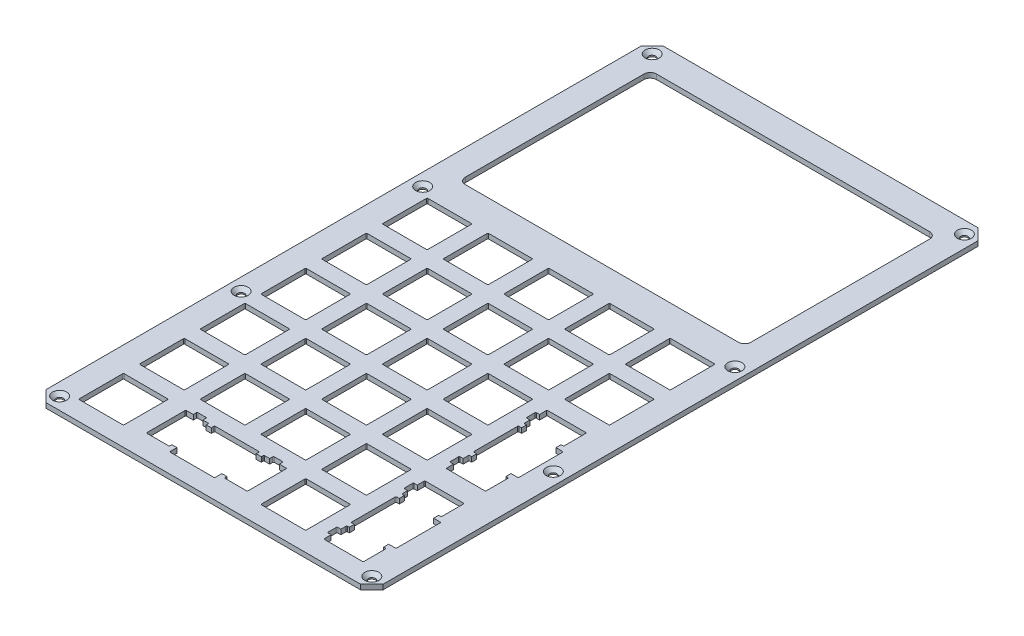
from build123d import *

# Parameters (mm, degrees)
SKETCH1_W           = 105
SKETCH1_H           = 192.3454
SKETCH1_W_2         = 13.9954
SKETCH1_H_2         = 13.9954
BOSS_EXTRUDE1_DEPTH = 1.524
FILLET1_R           = 0.25
CHAMFER1_SIZE       = 3.5
SKETCH3_R           = 1.1
CUT_EXTRUDE1_DEPTH  = 2.524
CHAMFER2_SIZE       = 1.1


with BuildPart() as part:
    # Sketch1 → Boss-Extrude1 (new body)
    with BuildSketch(Plane(origin=(0, 0, 0), x_dir=(1, 0, 0), z_dir=(0, 1, 0))):
        with Locations((37.846, -11.419)):
            Rectangle(SKETCH1_W, SKETCH1_H)
        Polygon((80.4243114, -40.3075), (82.6943114, -40.3075), (82.6943114, -54.3075), (80.4243114, -54.3075), (80.4243114, -55.8825), (81.2243114, -55.8825), (81.2243114, -63.0405), (68.9243114, -63.0405), (68.9243114, -60.7075), (67.7243114, -60.7075), (67.7243114, -57.7075), (68.9243114, -57.7075), (68.9243114, -55.8825), (69.7243114, -55.8825), (69.7243114, -54.3075), (68.6943, -54.3075), (68.6943, -40.3075), (69.7243114, -40.3075), (69.7243114, -38.7325), (68.9243114, -38.7325), (68.9243114, -36.9075), (67.7243114, -36.9075), (67.7243114, -33.9075), (68.9243114, -33.9075), (68.9243114, -31.5745), (81.2243114, -31.5745), (81.2243114, -38.7325), (80.4243114, -38.7325), align=None, mode=Mode.SUBTRACT)
        with Locations((0, -94.615)):
            Rectangle(SKETCH1_W_2, SKETCH1_H_2, mode=Mode.SUBTRACT)
        with Locations((0, -75.692)):
            Rectangle(SKETCH1_W_2, SKETCH1_H_2, mode=Mode.SUBTRACT)
        Polygon((21.3845, -87.6173), (35.3845, -87.6173), (35.3845, -88.6473114), (36.9595, -88.6473114), (36.9595, -87.8473114), (38.7845, -87.8473114), (38.7845, -86.6473114), (41.7845, -86.6473114), (41.7845, -87.8473114), (44.1175, -87.8473114), (44.1175, -100.1473114), (36.9595, -100.1473114), (36.9595, -99.3473114), (35.3845, -99.3473114), (35.3845, -101.6173114), (21.3845, -101.6173114), (21.3845, -99.3473114), (19.8095, -99.3473114), (19.8095, -100.1473114), (12.6515, -100.1473114), (12.6515, -87.8473114), (14.9845, -87.8473114), (14.9845, -86.6473114), (17.9845, -86.6473114), (17.9845, -87.8473114), (19.8095, -87.8473114), (19.8095, -88.6473114), (21.3845, -88.6473114), align=None, mode=Mode.SUBTRACT)
        with Locations((18.923, -75.692)):
            Rectangle(SKETCH1_W_2, SKETCH1_H_2, mode=Mode.SUBTRACT)
        with Locations((0, -56.769)):
            Rectangle(SKETCH1_W_2, SKETCH1_H_2, mode=Mode.SUBTRACT)
        with Locations((0, -37.846)):
            Rectangle(SKETCH1_W_2, SKETCH1_H_2, mode=Mode.SUBTRACT)
        with Locations((0, -18.923)):
            Rectangle(SKETCH1_W_2, SKETCH1_H_2, mode=Mode.SUBTRACT)
        with Locations((18.923, -56.769)):
            Rectangle(SKETCH1_W_2, SKETCH1_H_2, mode=Mode.SUBTRACT)
        with Locations((18.923, -37.846)):
            Rectangle(SKETCH1_W_2, SKETCH1_H_2, mode=Mode.SUBTRACT)
        with Locations((18.923, -18.923)):
            Rectangle(SKETCH1_W_2, SKETCH1_H_2, mode=Mode.SUBTRACT)
        with Locations((56.769, -94.615)):
            Rectangle(SKETCH1_W_2, SKETCH1_H_2, mode=Mode.SUBTRACT)
        with Locations((37.846, -75.692)):
            Rectangle(SKETCH1_W_2, SKETCH1_H_2, mode=Mode.SUBTRACT)
        with Locations((56.769, -75.692)):
            Rectangle(SKETCH1_W_2, SKETCH1_H_2, mode=Mode.SUBTRACT)
        Polygon((67.7243114, -72.0075), (68.9243114, -72.0075), (68.9243114, -69.6745), (81.2243114, -69.6745), (81.2243114, -76.8325), (80.4243114, -76.8325), (80.4243114, -78.4075), (82.6943114, -78.4075), (82.6943114, -92.4075), (80.4243114, -92.4075), (80.4243114, -93.9825), (81.2243114, -93.9825), (81.2243114, -101.1405), (68.9243114, -101.1405), (68.9243114, -98.8075), (67.7243114, -98.8075), (67.7243114, -95.8075), (68.9243114, -95.8075), (68.9243114, -93.9825), (69.7243114, -93.9825), (69.7243114, -92.4075), (68.6943, -92.4075), (68.6943, -78.4075), (69.7243114, -78.4075), (69.7243114, -76.8325), (68.9243114, -76.8325), (68.9243114, -75.0075), (67.7243114, -75.0075), align=None, mode=Mode.SUBTRACT)
        with Locations((37.846, -56.769)):
            Rectangle(SKETCH1_W_2, SKETCH1_H_2, mode=Mode.SUBTRACT)
        with Locations((37.846, -37.846)):
            Rectangle(SKETCH1_W_2, SKETCH1_H_2, mode=Mode.SUBTRACT)
        with Locations((56.769, -56.769)):
            Rectangle(SKETCH1_W_2, SKETCH1_H_2, mode=Mode.SUBTRACT)
        with Locations((56.769, -37.846)):
            Rectangle(SKETCH1_W_2, SKETCH1_H_2, mode=Mode.SUBTRACT)
        with Locations((37.846, -18.923)):
            Rectangle(SKETCH1_W_2, SKETCH1_H_2, mode=Mode.SUBTRACT)
        with Locations((56.769, -18.923)):
            Rectangle(SKETCH1_W_2, SKETCH1_H_2, mode=Mode.SUBTRACT)
        with BuildLine():
            Line((82.3656, 74.1637), (82.3656, 18.5377))
            ThreePointArc((82.3656, 18.5377), (81.779813562, 17.123486438), (80.3656, 16.5377))
            Line((80.3656, 16.5377), (-4.6736, 16.5377))
            ThreePointArc((-4.6736, 16.5377), (-6.087813562, 17.123486438), (-6.6736, 18.5377))
            Line((-6.6736, 18.5377), (-6.6736, 74.1637))
            ThreePointArc((-6.6736, 74.1637), (-6.087813562, 75.577913562), (-4.6736, 76.1637))
            Line((-4.6736, 76.1637), (80.3656, 76.1637))
            ThreePointArc((80.3656, 76.1637), (81.779813562, 75.577913562), (82.3656, 74.1637))
        make_face(mode=Mode.SUBTRACT)
        with Locations((75.692, -18.923)):
            Rectangle(SKETCH1_W_2, SKETCH1_H_2, mode=Mode.SUBTRACT)
        Rectangle(SKETCH1_W_2, SKETCH1_H_2, mode=Mode.SUBTRACT)
        with Locations((18.923, 0)):
            Rectangle(SKETCH1_W_2, SKETCH1_H_2, mode=Mode.SUBTRACT)
        with Locations((37.846, 0)):
            Rectangle(SKETCH1_W_2, SKETCH1_H_2, mode=Mode.SUBTRACT)
        with Locations((56.769, 0)):
            Rectangle(SKETCH1_W_2, SKETCH1_H_2, mode=Mode.SUBTRACT)
        with Locations((75.692, 0)):
            Rectangle(SKETCH1_W_2, SKETCH1_H_2, mode=Mode.SUBTRACT)
    extrude(amount=BOSS_EXTRUDE1_DEPTH)

    # Fillet1
    fillet1_edges = [part.edges().sort_by_distance(p)[0] for p in [
        (21.3845, 0.762, 87.6173),
        (19.8095, 0.762, 87.8473114),
        (17.9845, 0.762, 86.6473114),
        (14.9845, 0.762, 86.6473114),
        (12.6515, 0.762, 87.8473114),
        (12.6515, 0.762, 100.1473114),
        (19.8095, 0.762, 100.1473114),
        (21.3845, 0.762, 101.6173114),
        (35.3845, 0.762, 101.6173114),
        (36.9595, 0.762, 100.1473114),
        (44.1175, 0.762, 100.1473114),
        (44.1175, 0.762, 87.8473114),
        (41.7845, 0.762, 86.6473114),
        (38.7845, 0.762, 86.6473114),
        (36.9595, 0.762, 87.8473114),
        (35.3845, 0.762, 87.6173),
        (68.6943, 0.762, 92.4075),
        (68.9243114, 0.762, 93.9825),
        (67.7243114, 0.762, 95.8075),
        (67.7243114, 0.762, 98.8075),
        (68.9243114, 0.762, 101.1405),
        (81.2243114, 0.762, 101.1405),
        (81.2243114, 0.762, 93.9825),
        (82.6943114, 0.762, 92.4075),
        (82.6943114, 0.762, 78.4075),
        (81.2243114, 0.762, 76.8325),
        (81.2243114, 0.762, 69.6745),
        (68.9243114, 0.762, 69.6745),
        (67.7243114, 0.762, 72.0075),
        (67.7243114, 0.762, 75.0075),
        (68.9243114, 0.762, 76.8325),
        (68.6943, 0.762, 78.4075),
        (68.6943, 0.762, 54.3075),
        (68.9243114, 0.762, 55.8825),
        (67.7243114, 0.762, 57.7075),
        (67.7243114, 0.762, 60.7075),
        (68.9243114, 0.762, 63.0405),
        (81.2243114, 0.762, 63.0405),
        (81.2243114, 0.762, 55.8825),
        (82.6943114, 0.762, 54.3075),
        (82.6943114, 0.762, 40.3075),
        (81.2243114, 0.762, 38.7325),
        (81.2243114, 0.762, 31.5745),
        (68.9243114, 0.762, 31.5745),
        (67.7243114, 0.762, 33.9075),
        (67.7243114, 0.762, 36.9075),
        (68.9243114, 0.762, 38.7325),
        (68.6943, 0.762, 40.3075),
        (6.9977, 0.762, 6.9977),
        (6.9977, 0.762, -6.9977),
        (-6.9977, 0.762, -6.9977),
        (-6.9977, 0.762, 6.9977),
        (11.9253, 0.762, -6.9977),
        (11.9253, 0.762, 6.9977),
        (25.9207, 0.762, 6.9977),
        (25.9207, 0.762, -6.9977),
        (30.8483, 0.762, -6.9977),
        (30.8483, 0.762, 6.9977),
        (44.8437, 0.762, 6.9977),
        (44.8437, 0.762, -6.9977),
        (49.7713, 0.762, -6.9977),
        (49.7713, 0.762, 6.9977),
        (63.7667, 0.762, 6.9977),
        (63.7667, 0.762, -6.9977),
        (68.6943, 0.762, -6.9977),
        (68.6943, 0.762, 6.9977),
        (82.6897, 0.762, 6.9977),
        (82.6897, 0.762, -6.9977),
        (11.9253, 0.762, 11.9253),
        (11.9253, 0.762, 25.9207),
        (25.9207, 0.762, 25.9207),
        (25.9207, 0.762, 11.9253),
        (30.8483, 0.762, 11.9253),
        (30.8483, 0.762, 25.9207),
        (44.8437, 0.762, 25.9207),
        (44.8437, 0.762, 11.9253),
        (49.7713, 0.762, 11.9253),
        (49.7713, 0.762, 25.9207),
        (63.7667, 0.762, 25.9207),
        (63.7667, 0.762, 11.9253),
        (68.6943, 0.762, 11.9253),
        (68.6943, 0.762, 25.9207),
        (82.6897, 0.762, 25.9207),
        (82.6897, 0.762, 11.9253),
        (11.9253, 0.762, 30.8483),
        (11.9253, 0.762, 44.8437),
        (25.9207, 0.762, 44.8437),
        (25.9207, 0.762, 30.8483),
        (30.8483, 0.762, 30.8483),
        (30.8483, 0.762, 44.8437),
        (44.8437, 0.762, 44.8437),
        (44.8437, 0.762, 30.8483),
        (49.7713, 0.762, 30.8483),
        (49.7713, 0.762, 44.8437),
        (63.7667, 0.762, 44.8437),
        (63.7667, 0.762, 30.8483),
        (11.9253, 0.762, 49.7713),
        (11.9253, 0.762, 63.7667),
        (25.9207, 0.762, 63.7667),
        (25.9207, 0.762, 49.7713),
        (30.8483, 0.762, 49.7713),
        (30.8483, 0.762, 63.7667),
        (44.8437, 0.762, 63.7667),
        (44.8437, 0.762, 49.7713),
        (49.7713, 0.762, 49.7713),
        (49.7713, 0.762, 63.7667),
        (63.7667, 0.762, 63.7667),
        (63.7667, 0.762, 49.7713),
        (11.9253, 0.762, 68.6943),
        (11.9253, 0.762, 82.6897),
        (25.9207, 0.762, 82.6897),
        (25.9207, 0.762, 68.6943),
        (30.8483, 0.762, 68.6943),
        (30.8483, 0.762, 82.6897),
        (44.8437, 0.762, 82.6897),
        (44.8437, 0.762, 68.6943),
        (49.7713, 0.762, 68.6943),
        (49.7713, 0.762, 82.6897),
        (63.7667, 0.762, 82.6897),
        (63.7667, 0.762, 68.6943),
        (49.7713, 0.762, 87.6173),
        (49.7713, 0.762, 101.6127),
        (63.7667, 0.762, 101.6127),
        (63.7667, 0.762, 87.6173),
        (-6.9977, 0.762, 11.9253),
        (-6.9977, 0.762, 25.9207),
        (6.9977, 0.762, 25.9207),
        (6.9977, 0.762, 11.9253),
        (-6.9977, 0.762, 30.8483),
        (-6.9977, 0.762, 44.8437),
        (6.9977, 0.762, 44.8437),
        (6.9977, 0.762, 30.8483),
        (-6.9977, 0.762, 49.7713),
        (-6.9977, 0.762, 63.7667),
        (6.9977, 0.762, 63.7667),
        (6.9977, 0.762, 49.7713),
        (-6.9977, 0.762, 68.6943),
        (-6.9977, 0.762, 82.6897),
        (6.9977, 0.762, 82.6897),
        (6.9977, 0.762, 68.6943),
        (-6.9977, 0.762, 87.6173),
        (-6.9977, 0.762, 101.6127),
        (6.9977, 0.762, 101.6127),
        (6.9977, 0.762, 87.6173),
    ]]
    fillet(fillet1_edges, radius=FILLET1_R)

    # Chamfer1
    chamfer1_edges = [part.edges().sort_by_distance(p)[0] for p in [
        (90.346, 0.762, 107.5917),
        (-14.654, 0.762, 107.5917),
        (-14.654, 0.762, -84.7537),
        (90.346, 0.762, -84.7537),
    ]]
    chamfer(chamfer1_edges, length=CHAMFER1_SIZE)

    # Sketch3 → Cut-Extrude1 (cut, through all)
    with BuildSketch(Plane(origin=(0, 1.524, 0), x_dir=(1, 0, 0), z_dir=(0, 1, 0))):
        with Locations((-10.782679656, 9.382379656)):
            Circle(SKETCH3_R)
        with Locations((86.474679656, -103.720379656)):
            Circle(SKETCH3_R)
        with Locations((-10.782679656, -103.720379656)):
            Circle(SKETCH3_R)
        with Locations((-10.782679656, -47.169)):
            Circle(SKETCH3_R)
        with Locations((-10.782679656, 80.882379656)):
            Circle(SKETCH3_R)
        with Locations((86.474679656, 80.882379656)):
            Circle(SKETCH3_R)
        with Locations((86.474679656, 9.382379656)):
            Circle(SKETCH3_R)
        with Locations((86.474679656, -47.169)):
            Circle(SKETCH3_R)
    extrude(amount=-CUT_EXTRUDE1_DEPTH, mode=Mode.SUBTRACT)

    # Chamfer2
    chamfer2_edges = [part.edges().sort_by_distance(p)[0] for p in [
        (85.374679656, 1.524, 103.720379656),
        (-11.882679656, 1.524, 103.720379656),
        (-11.882679656, 1.524, 47.169),
        (-11.882679656, 1.524, -80.882379656),
        (85.374679656, 1.524, -80.882379656),
        (85.374679656, 1.524, -9.382379656),
        (85.374679656, 1.524, 47.169),
        (-11.882679656, 1.524, -9.382379656),
    ]]
    chamfer(chamfer2_edges, length=CHAMFER2_SIZE)


solid = part.part
